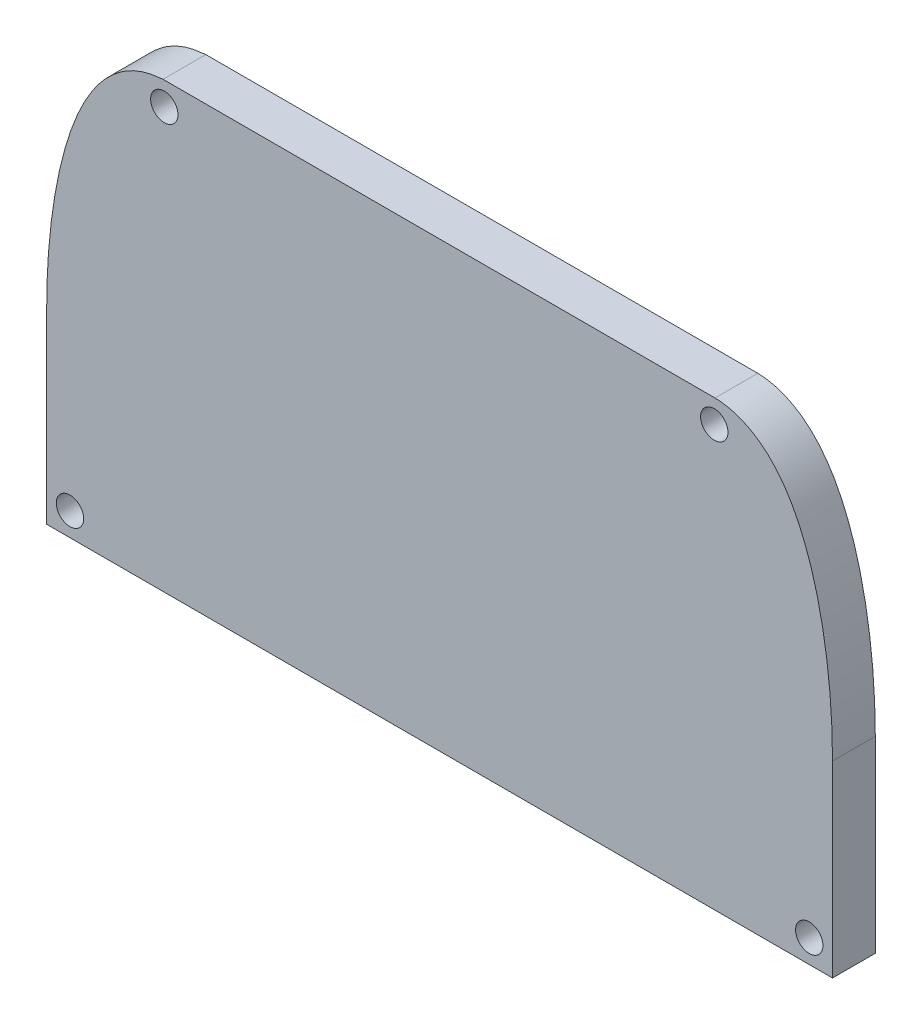
from build123d import *

# Parameters (mm, degrees)
BOSS_EXTRUDE1_DEPTH = 3.125
SKETCH2_R           = 1
CUT_EXTRUDE1_DEPTH  = 4.1250001


with BuildPart() as part:
    # Sketch1 → Boss-Extrude1 (new body)
    with BuildSketch(Plane.XY):
        with BuildLine():
            Line((-20.203129901, 38.877510312), (20.117155087, 38.877510312))
            add(Edge.make_bspline(
                [(20.117155087, 38.877510312), (21.156749182, 38.850767463), (22.735886033, 38.191125375), (23.719947817, 37.486220747), (24.317353218, 36.912931858), (24.792221965, 36.370922804), (25.193772441, 35.834092453), (25.580242779, 35.238947111), (25.880693088, 34.70853854), (26.075964251, 34.329555217), (26.27578321, 33.917456134), (26.50283091, 33.407963298), (26.759971615, 32.767993983), (27.000050863, 32.102166694), (27.232629316, 31.379979175), (27.41356127, 30.755323796), (27.590811467, 30.080987437), (27.755431361, 29.385748212), (27.912775159, 28.644354852), (28.03910053, 27.980953625), (28.187039057, 27.115480867), (28.36478274, 25.857510545), (28.514705173, 24.455074496), (28.609846111, 23.205425502), (28.647832076, 22.444063797), (28.662990893, 22.038674751), (28.670134973, 21.812401374), (28.675595709, 21.613399304), (28.678245622, 21.502621455), (28.682159819, 21.324092236), (28.692138153, 20.796374144), (28.7, 20.201919543)],
                knots=[0.00028808, 0.00028808, 0.00028808, 0.094004972, 0.1564829, 0.203341346, 0.23458031, 0.265819274, 0.297058238, 0.328297202, 0.351726425, 0.367345907, 0.39077513, 0.422014094, 0.453253058, 0.484492022, 0.515730986, 0.54696995, 0.578208914, 0.609447878, 0.640686842, 0.671925806, 0.718784252, 0.78126218, 0.843740108, 0.890598554, 0.914027777, 0.925742389, 0.93355213, 0.941361871, 0.949171612, 0.960886223, 0.999934928, 0.999934928, 0.999934928], degree=2))
            Line((28.7, 20.201919543), (28.7, 6.477510312))
            Line((28.7, 6.477510312), (-28.7, 6.477510312))
            Line((-28.7, 6.477510312), (-28.7, 20.201963546))
            add(Edge.make_bspline(
                [(-28.7, 20.201963546), (-28.692153994, 20.794156459), (-28.682233134, 21.319666669), (-28.678344818, 21.497465649), (-28.675719654, 21.607561496), (-28.670287973, 21.806287867), (-28.663195669, 22.031980185), (-28.648165574, 22.436044498), (-28.610616915, 23.192828113), (-28.516251433, 24.438176441), (-28.367453676, 25.834827406), (-28.192228084, 27.081685513), (-28.046559562, 27.939579815), (-27.922133003, 28.597483896), (-27.768098497, 29.328930146), (-27.606982401, 30.015782704), (-27.433563779, 30.682500172), (-27.257332943, 31.29834509), (-27.02692461, 32.023081071), (-26.789775764, 32.689408082), (-26.535986502, 33.329426687), (-26.279546608, 33.913339435), (-25.947227657, 34.587755578), (-25.626984432, 35.161228543), (-25.234153605, 35.776093613), (-24.838872765, 36.312799127), (-24.37687249, 36.849479287), (-23.771614433, 37.440093914), (-22.81027432, 38.154312676), (-21.778778312, 38.593984534), (-21.23657709, 38.729347669), (-20.629937031, 38.842543263), (-20.203129901, 38.877510312)],
                knots=[6.5431e-05, 6.5431e-05, 6.5431e-05, 0.039109453, 0.05082266, 0.058631465, 0.066440269, 0.074249074, 0.08596228, 0.109388694, 0.15624152, 0.218711956, 0.281182392, 0.328035219, 0.359270437, 0.390505655, 0.421740872, 0.45297609, 0.484211308, 0.515446526, 0.546681744, 0.577916962, 0.60915218, 0.640387398, 0.671622615, 0.702857833, 0.734093051, 0.765328269, 0.796563487, 0.843416314, 0.90588675, 0.944930772, 0.960548381, 0.999592403, 0.999592403, 0.999592403], degree=2))
        make_face()
    extrude(amount=BOSS_EXTRUDE1_DEPTH)

    # Sketch2 → Cut-Extrude1 (cut, through all)
    with BuildSketch(Plane.XY.offset(3.125)):
        with Locations((-27, 8.177510312)):
            Circle(SKETCH2_R)
        with Locations((-20.109740551, 37.177510312)):
            Circle(SKETCH2_R)
        with Locations((20.062840726, 37.177510312)):
            Circle(SKETCH2_R)
        with Locations((27, 8.177510312)):
            Circle(SKETCH2_R)
    extrude(amount=-CUT_EXTRUDE1_DEPTH, mode=Mode.SUBTRACT)


solid = part.part
